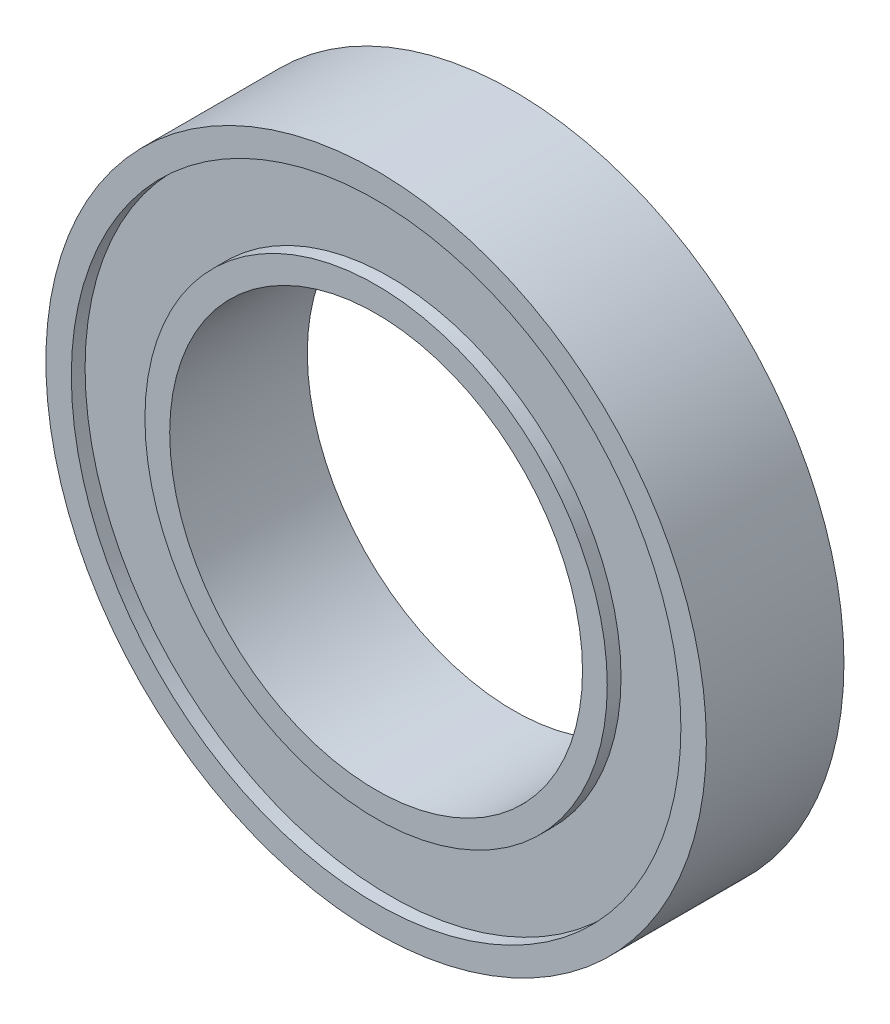
from build123d import *

# Parameters (mm, degrees)
SKETCH_1_R          = 12
EXTRUDE_1_DEPTH     = 5
SKETCH_2_R          = 7.5
CUT_EXTRUDE_1_DEPTH = 6
SKETCH_3_R          = 11.075
SKETCH_3_R_2        = 8.4
CUT_EXTRUDE_2_DEPTH = 0.5
SKETCH_4_R          = 11.075
SKETCH_4_R_2        = 8.4
CUT_EXTRUDE_3_DEPTH = 0.5


with BuildPart() as part:
    # 草圖1 → 填料-伸長1 (new body)
    with BuildSketch(Plane.XY):
        Circle(SKETCH_1_R)
    extrude(amount=EXTRUDE_1_DEPTH)

    # 草圖2 → 除料-伸長1 (cut, through all)
    with BuildSketch(Plane.XY.offset(5)):
        Circle(SKETCH_2_R)
    extrude(amount=-CUT_EXTRUDE_1_DEPTH, mode=Mode.SUBTRACT)

    # 草圖3 → 除料-伸長2 (cut)
    with BuildSketch(Plane.XY.offset(5)):
        Circle(SKETCH_3_R)
        Circle(SKETCH_3_R_2, mode=Mode.SUBTRACT)
    extrude(amount=-CUT_EXTRUDE_2_DEPTH, mode=Mode.SUBTRACT)

    # 草圖4 → 除料-伸長3 (cut)
    with BuildSketch(Plane(origin=(0, 0, 0), x_dir=(-1, 0, 0), z_dir=(0, 0, -1))):
        Circle(SKETCH_4_R)
        Circle(SKETCH_4_R_2, mode=Mode.SUBTRACT)
    extrude(amount=-CUT_EXTRUDE_3_DEPTH, mode=Mode.SUBTRACT)


solid = part.part
